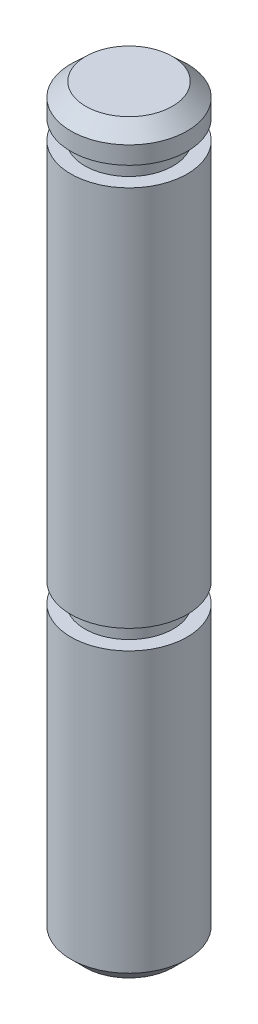
from build123d import *


with BuildPart() as part:
    # Sketch2 → Revolve4 (revolve)
    with BuildSketch(Plane.XY):
        Polygon((-1.5875, -5.207), (-1.5875, 5.207), (-1.2065, 5.207), (-1.2065, 5.7404), (-1.5875, 5.7404), (-1.5875, 6.223), (-1.182787561, 6.604), (0, 6.604), (0, -6.604), (0, -13.7414), (-1.2065, -13.7414), (-1.5875, -13.3604), (-1.5875, -5.7404), (-1.2065, -5.7404), (-1.2065, -5.207), align=None)
    revolve(axis=Axis((0, 0, 0), (0, 1, 0)))


solid = part.part
